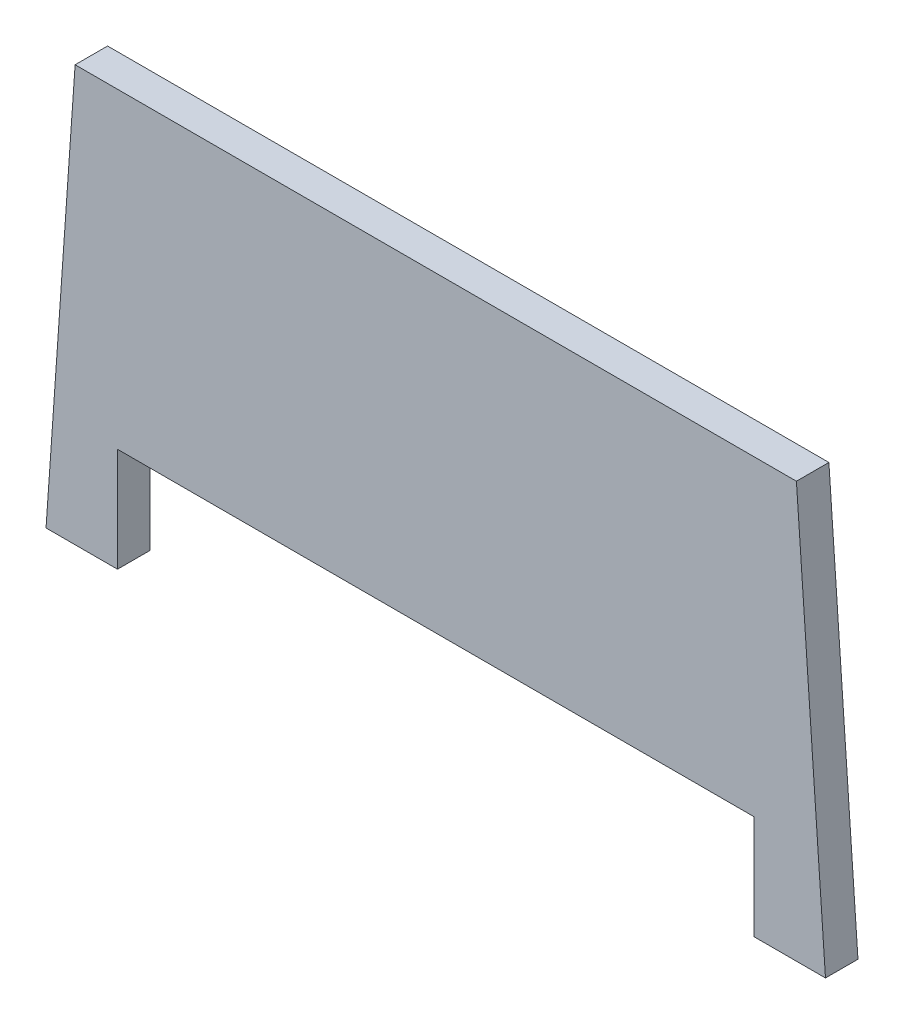
from build123d import *

# Parameters (mm, degrees)
BOSS_EXTRUDE1_DEPTH = 25
SKETCH3_W           = 80
SKETCH3_H           = 80
CUT_EXTRUDE2_DEPTH  = 26


with BuildPart() as part:
    # Sketch1 → Boss-Extrude1 (new body)
    with BuildSketch(Plane.XY):
        Polygon((50, 0), (185, 0), (185, 80), (515, 80), (515, 0), (650, 0), (627.623420178, 320), (72.376579822, 320), align=None)
    extrude(amount=BOSS_EXTRUDE1_DEPTH)

    # Sketch3 → Cut-Extrude2 (cut, through all)
    with BuildSketch(Plane.XY.offset(25)):
        with Locations((145, 40)):
            Rectangle(SKETCH3_W, SKETCH3_H)
        with Locations((555, 40)):
            Rectangle(SKETCH3_W, SKETCH3_H)
    extrude(amount=-CUT_EXTRUDE2_DEPTH, mode=Mode.SUBTRACT)


solid = part.part
